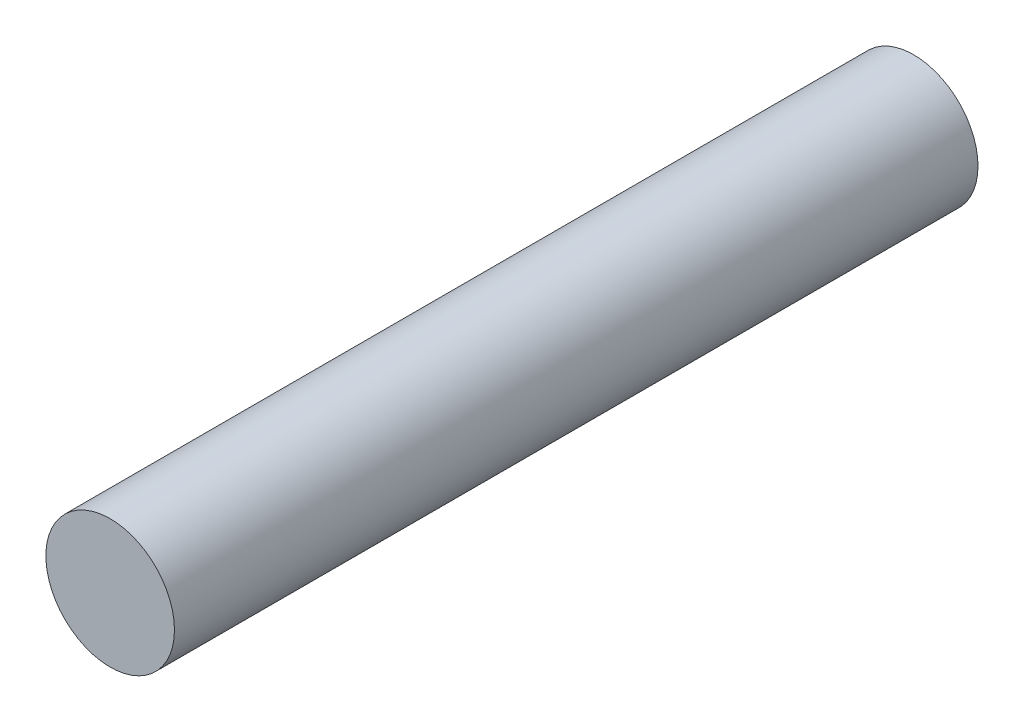
from build123d import *

# Parameters (mm, degrees)
SKETCH_1_R      = 4
EXTRUDE_1_DEPTH = 50


with BuildPart() as part:
    # 草圖1 → 填料-伸長1 (new body)
    with BuildSketch(Plane.XY):
        Circle(SKETCH_1_R)
    extrude(amount=EXTRUDE_1_DEPTH)


solid = part.part
